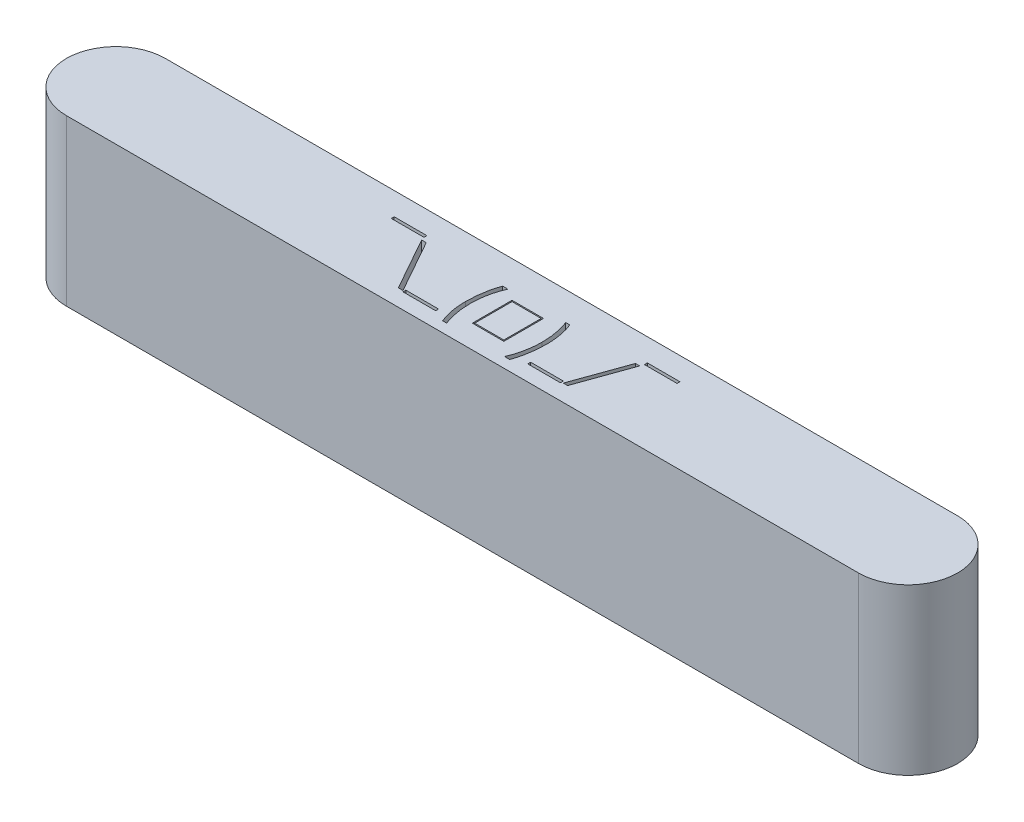
from build123d import *

# Parameters (mm, degrees)
BOSS_EXTRUDE1_DEPTH = 12.7
CUT_EXTRUDE1_DEPTH  = 10.16
SKETCH3_W           = 2.512820512
SKETCH3_H           = 0.224358975
SKETCH3_W_2         = 2.512820513
SKETCH3_H_2         = 0.224358974
SKETCH3_W_3         = 2.423076923
SKETCH3_H_3         = 3.051282052
SKETCH3_W_4         = 2.243589743
SKETCH3_H_4         = 2.871794872
CUT_EXTRUDE2_DEPTH  = 1.27


with BuildPart() as part:
    # Sketch1 → Boss-Extrude1 (new body)
    with BuildSketch(Plane(origin=(0, 0, 0), x_dir=(1, 0, 0), z_dir=(0, 1, 0))):
        with BuildLine():
            Line((-30.48, 3.81), (30.48, 3.81))
            ThreePointArc((30.48, 3.81), (34.29, 0), (30.48, -3.81))
            Line((30.48, -3.81), (-30.48, -3.81))
            ThreePointArc((-30.48, -3.81), (-34.29, 0), (-30.48, 3.81))
        make_face()
    extrude(amount=BOSS_EXTRUDE1_DEPTH)

    # Sketch2 → Cut-Extrude1 (cut)
    with BuildSketch(Plane.XZ):
        with BuildLine():
            Line((-30.988, 1.397), (30.988, 1.397))
            ThreePointArc((30.988, 1.397), (32.385, 0), (30.988, -1.397))
            Line((30.988, -1.397), (-30.988, -1.397))
            ThreePointArc((-30.988, -1.397), (-32.385, 0), (-30.988, 1.397))
        make_face()
    extrude(amount=-CUT_EXTRUDE1_DEPTH, mode=Mode.SUBTRACT)

    # Sketch3 → Cut-Extrude2 (cut)
    with BuildSketch(Plane(origin=(0, 12.7, 0), x_dir=(1, 0, 0), z_dir=(0, 1, 0))):
        with Locations((-9.868354695, 1.949821987)):
            Rectangle(SKETCH3_W, SKETCH3_H)
        Polygon((-8.167433221, 1.56841173), (-5.874764951, -2.514921603), (-6.22953258, -2.514921603), (-8.522200849, 1.56841173), align=None)
        with Locations((-4.528611106, -2.492485706)):
            Rectangle(SKETCH3_W_2, SKETCH3_H_2)
        with BuildLine():
            Line((-2.329893156, 1.613283525), (-1.926047003, 1.613283525))
            add(Edge.make_bspline(
                [(-1.926047003, 1.613283525), (-1.944595679, 1.573225506), (-1.982258533, 1.491888205), (-2.033440085, 1.365776004), (-2.08306669, 1.235347225), (-2.128016891, 1.099286858), (-2.172746394, 0.958938117), (-2.212892282, 0.813055443), (-2.251030023, 0.662573196), (-2.297658473, 0.455059227), (-2.346937221, 0.189956446), (-2.388844661, -0.13371939), (-2.414835709, -0.462309009), (-2.418031025, -0.683310365), (-2.419636746, -0.794368719)],
                knots=[0, 0, 0, 0, 0.000132414, 0.000268864, 0.000408202, 0.000550987, 0.000698673, 0.00085007, 0.001004813, 0.001164361, 0.001488072, 0.00181332, 0.002143114, 0.002476253, 0.002476253, 0.002476253, 0.002476253], degree=3))
            add(Edge.make_bspline(
                [(-2.419636746, -0.794368719), (-2.418174092, -0.896994356), (-2.415269461, -1.100794888), (-2.39555112, -1.403593934), (-2.361748279, -1.700924317), (-2.315161311, -1.990560634), (-2.257008203, -2.26887028), (-2.187308319, -2.531522985), (-2.109429056, -2.777644099), (-2.046451105, -2.932917324), (-2.015790592, -3.008511347)],
                knots=[0, 0, 0, 0, 0.000307872, 0.000611392, 0.00090987, 0.001205296, 0.001491175, 0.001762426, 0.002020291, 0.002264936, 0.002264936, 0.002264936, 0.002264936], degree=3))
            Line((-2.015790592, -3.008511347), (-2.329893156, -3.008511347))
            add(Edge.make_bspline(
                [(-2.329893156, -3.008511347), (-2.345059433, -2.972840264), (-2.375799242, -2.900540233), (-2.418668441, -2.788874123), (-2.458438817, -2.672275035), (-2.496197017, -2.551137941), (-2.531986826, -2.425372334), (-2.565708096, -2.295224557), (-2.596352522, -2.160231418), (-2.635037976, -1.973771045), (-2.674487586, -1.734133797), (-2.708879678, -1.441012576), (-2.729583163, -1.141957485), (-2.732346302, -0.940701584), (-2.73373931, -0.839240513)],
                knots=[0, 0, 0, 0, 0.000116278, 0.000235679, 0.000358736, 0.000485801, 0.000616297, 0.000750978, 0.000889083, 0.001031536, 0.001322232, 0.001617307, 0.001916676, 0.002221044, 0.002221044, 0.002221044, 0.002221044], degree=3))
            add(Edge.make_bspline(
                [(-2.73373931, -0.839240513), (-2.732594304, -0.729601973), (-2.730314646, -0.511316432), (-2.709927037, -0.186438945), (-2.67775989, 0.134220277), (-2.63330287, 0.449137671), (-2.576047932, 0.75631684), (-2.506720854, 1.052993625), (-2.425998034, 1.33841465), (-2.36165775, 1.522433838), (-2.329893156, 1.613283525)],
                knots=[0, 0, 0, 0, 0.000328887, 0.000654799, 0.000976133, 0.001295507, 0.001608623, 0.001913212, 0.002209258, 0.002497933, 0.002497933, 0.002497933, 0.002497933], degree=3))
        make_face()
        with Locations((0.182927357, -0.495690834)):
            Rectangle(SKETCH3_W_3, SKETCH3_H_3)
        with Locations((0.182927357, -0.495690834)):
            Rectangle(SKETCH3_W_4, SKETCH3_H_4, mode=Mode.SUBTRACT)
        with BuildLine():
            Line((2.830363254, -3.008511347), (2.4265171, -3.008511347))
            add(Edge.make_bspline(
                [(2.4265171, -3.008511347), (2.445363004, -2.968481706), (2.483586773, -2.887292514), (2.534455272, -2.76084909), (2.584889971, -2.630579527), (2.630978179, -2.494786752), (2.674142382, -2.354187151), (2.715314887, -2.208721317), (2.751721509, -2.058090142), (2.799164465, -1.850839452), (2.848318586, -1.585696239), (2.889036553, -1.261679417), (2.915372484, -0.932926529), (2.918523423, -0.711920038), (2.920106844, -0.600859103)],
                knots=[0, 0, 0, 0, 0.000132705, 0.000269155, 0.000408742, 0.000551752, 0.000699229, 0.000849951, 0.001005205, 0.001164069, 0.001487781, 0.001813634, 0.002143428, 0.002476567, 0.002476567, 0.002476567, 0.002476567], degree=3))
            add(Edge.make_bspline(
                [(2.920106844, -0.600859103), (2.918636197, -0.498001444), (2.91572232, -0.294203706), (2.896183473, 0.008881128), (2.861380724, 0.305887024), (2.815003035, 0.595585979), (2.756388988, 0.873712258), (2.688249953, 1.13672272), (2.609689621, 1.382585825), (2.546879933, 1.537677511), (2.51626069, 1.613283525)],
                knots=[0, 0, 0, 0, 0.000308573, 0.000611394, 0.000910648, 0.001205381, 0.001491261, 0.001763011, 0.002020209, 0.002264854, 0.002264854, 0.002264854, 0.002264854], degree=3))
            Line((2.51626069, 1.613283525), (2.830363254, 1.613283525))
            add(Edge.make_bspline(
                [(2.830363254, 1.613283525), (2.845822151, 1.577637011), (2.877117965, 1.505472313), (2.919829121, 1.393322705), (2.960040307, 1.276737462), (2.999155723, 1.155636367), (3.034577994, 1.029732856), (3.067427606, 0.898965664), (3.098479857, 0.763700098), (3.135574411, 0.576263016), (3.175988281, 0.336649903), (3.209135848, 0.043155631), (3.230099589, -0.255833632), (3.232832988, -0.457328041), (3.234209408, -0.558791796)],
                knots=[0, 0, 0, 0, 0.000116551, 0.000235952, 0.0003599, 0.000486508, 0.000617678, 0.000752185, 0.000890974, 0.001033975, 0.001325362, 0.00161966, 0.001919729, 0.002224096, 0.002224096, 0.002224096, 0.002224096], degree=3))
            add(Edge.make_bspline(
                [(3.234209408, -0.558791796), (3.233086955, -0.66819864), (3.230857007, -0.885554545), (3.210174372, -1.209702469), (3.178588831, -1.529761994), (3.132817504, -1.84453593), (3.075650132, -2.151444658), (3.007392512, -2.448324515), (2.926416312, -2.733629989), (2.86211072, -2.917657534), (2.830363254, -3.008511347)],
                knots=[0, 0, 0, 0, 0.000328186, 0.000651998, 0.00097403, 0.001292809, 0.001605925, 0.001910355, 0.002206401, 0.002495076, 0.002495076, 0.002495076, 0.002495076], degree=3))
        make_face()
        with Locations((5.073952998, -2.492485706)):
            Rectangle(SKETCH3_W_2, SKETCH3_H_2)
        Polygon((8.259850433, 1.56841173), (6.795908126, -2.514921603), (6.464978638, -2.514921603), (7.928920946, 1.56841173), align=None)
        with Locations((9.60600428, 1.949821987)):
            Rectangle(SKETCH3_W_2, SKETCH3_H)
    extrude(amount=-CUT_EXTRUDE2_DEPTH, mode=Mode.SUBTRACT)


solid = part.part
